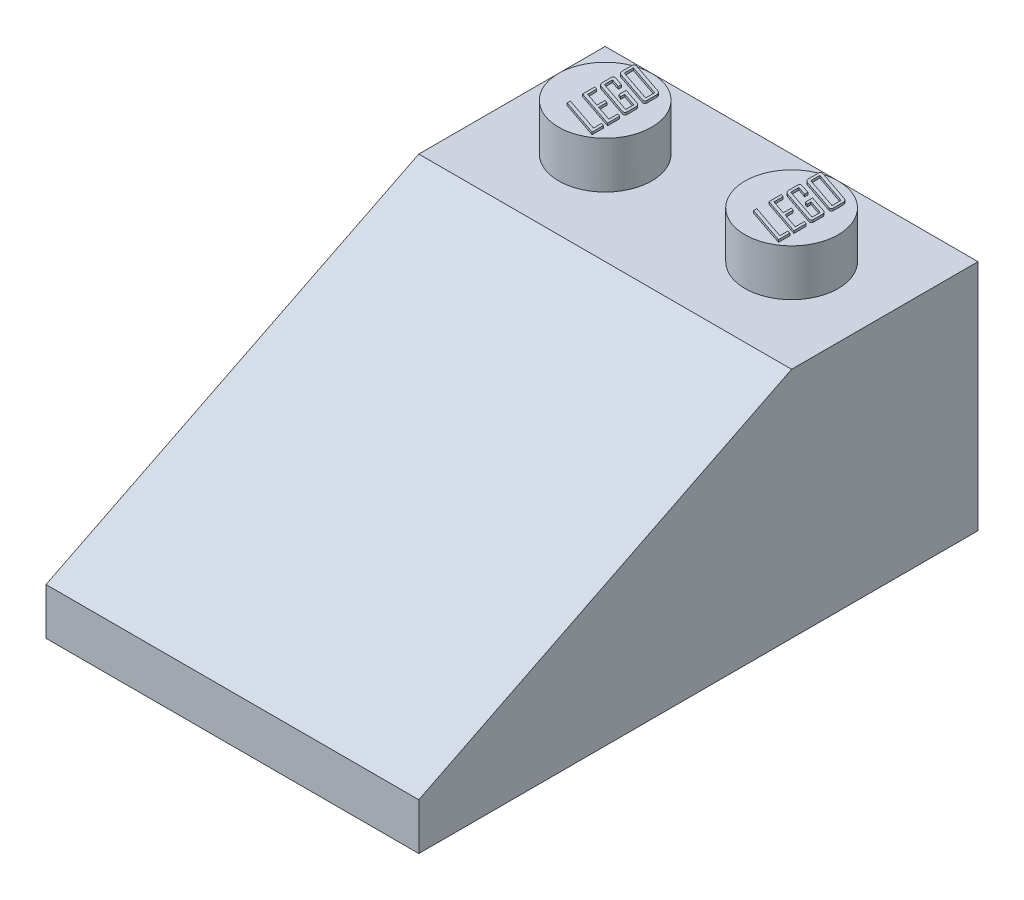
from build123d import *

# Parameters (mm, degrees)
BOSS_EXTRUDE1_DEPTH = 16
SKETCH2_R           = 2
BOSS_EXTRUDE2_DEPTH = 2
SHELL1_T            = -1
BOSS_EXTRUDE3_REACH = 14
SKETCH3_R           = 2.7
SKETCH3_R_2         = 1.7
BOSS_EXTRUDE6_DEPTH = 0.1
BOSS_EXTRUDE7_DEPTH = 0.1


with BuildPart() as part:
    # Sketch1 → Boss-Extrude1 (new body)
    with BuildSketch(Plane(origin=(0, 0, 0), x_dir=(0, 0, -1), z_dir=(1, 0, 0))):
        Polygon((-24, 0), (0, 0), (0, 10), (-8, 10), (-24, 2), align=None)
    extrude(amount=BOSS_EXTRUDE1_DEPTH)

    # Sketch2 → Boss-Extrude2 (add)
    with BuildSketch(Plane(origin=(0, 10, 0), x_dir=(1, 0, 0), z_dir=(0, 1, 0))):
        with Locations((4, -4)):
            Circle(SKETCH2_R)
        with Locations((12, -4)):
            Circle(SKETCH2_R)
    extrude(amount=BOSS_EXTRUDE2_DEPTH)

    # Shell1
    shell1_openings = [part.faces().sort_by_distance(p)[0] for p in [
        (8, 0, 12),
    ]]
    offset(amount=SHELL1_T, openings=shell1_openings, kind=Kind.INTERSECTION)

    # Sketch3 → Boss-Extrude3 (add, up to next)
    with BuildSketch(Plane.XZ, mode=Mode.PRIVATE) as boss_extrude3_sk1:
        with Locations((8, 8)):
            Circle(SKETCH3_R)
        with Locations((8, 8)):
            Circle(SKETCH3_R_2, mode=Mode.SUBTRACT)
    boss_extrude3_tool1 = extrude(boss_extrude3_sk1.sketch, amount=-BOSS_EXTRUDE3_REACH, mode=Mode.PRIVATE) - part.part
    add(boss_extrude3_tool1.solids().sort_by_distance((5.376368, 0, 8))[0])
    # Sketch3 → Boss-Extrude3 (add, up to next)
    with BuildSketch(Plane.XZ, mode=Mode.PRIVATE) as boss_extrude3_sk2:
        with Locations((8, 16)):
            Circle(SKETCH3_R)
        with Locations((8, 16)):
            Circle(SKETCH3_R_2, mode=Mode.SUBTRACT)
    boss_extrude3_tool2 = extrude(boss_extrude3_sk2.sketch, amount=-BOSS_EXTRUDE3_REACH, mode=Mode.PRIVATE) - part.part
    add(boss_extrude3_tool2.solids().sort_by_distance((5.376368, 0, 16))[0])

    # Sketch4 → Boss-Extrude6 (add)
    with BuildSketch(Plane(origin=(0, 12, 0), x_dir=(1, 0, 0), z_dir=(0, 1, 0))):
        Polygon((5, -5.07639621), (5, -5.563586671), (3.382527669, -5.013974932), (3.382527669, -4.877561603), (4.883074289, -5.387284623), (4.883074289, -5.036507491), align=None)
        Polygon((5, -4.375816327), (5, -4.901982025), (3.382527669, -4.352370286), (3.382527669, -3.826204588), (3.49945338, -3.865788813), (3.49945338, -4.255541182), (4.103569552, -4.460770163), (4.103569552, -4.109993032), (4.220495262, -4.149881751), (4.220495262, -4.500658882), (4.883074289, -4.725679977), (4.883074289, -4.335927608), align=None)
        with BuildLine():
            add(Edge.make_bspline(
                [(4.880638337, -3.517813026), (4.889199859, -3.521081683), (4.906042929, -3.527512106), (4.928863276, -3.542064932), (4.949502835, -3.559372092), (4.966947172, -3.580182774), (4.981499259, -3.602746648), (4.992465511, -3.626650767), (4.998722026, -3.651879609), (4.999570898, -3.669012008), (5, -3.677672396)],
                knots=[0, 0, 0, 0, 2.7428e-05, 5.3959e-05, 8.0744e-05, 0.000107959, 0.000135072, 0.000161104, 0.000186509, 0.000212479, 0.000212479, 0.000212479, 0.000212479], degree=3))
            Line((5, -3.677672396), (5, -4.06255286))
            add(Edge.make_bspline(
                [(5, -4.06255286), (4.999606754, -4.070705946), (4.998866417, -4.086055188), (4.992979137, -4.107517184), (4.981844322, -4.124889212), (4.967036047, -4.138214779), (4.948801843, -4.147092769), (4.927819264, -4.150147032), (4.904591861, -4.148459065), (4.888995283, -4.143873728), (4.880638337, -4.141416816)],
                knots=[0, 0, 0, 0, 2.4453e-05, 4.6035e-05, 6.5886e-05, 8.5509e-05, 0.000105119, 0.000125794, 0.000148378, 0.000174447, 0.000174447, 0.000174447, 0.000174447], degree=3))
            Line((4.880638337, -4.141416816), (3.501889332, -3.672800492))
            add(Edge.make_bspline(
                [(3.501889332, -3.672800492), (3.4933245, -3.669536063), (3.476474918, -3.663113957), (3.453757702, -3.648535645), (3.432927685, -3.631470812), (3.415304159, -3.610808853), (3.40056938, -3.588179121), (3.390203588, -3.56395811), (3.383773024, -3.53874798), (3.382945819, -3.521606234), (3.382527669, -3.512941121)],
                knots=[0, 0, 0, 0, 2.7428e-05, 5.3959e-05, 8.0548e-05, 0.000107961, 0.000135075, 0.000161263, 0.000186668, 0.000212637, 0.000212637, 0.000212637, 0.000212637], degree=3))
            Line((3.382527669, -3.512941121), (3.382527669, -3.128060657))
            add(Edge.make_bspline(
                [(3.382527669, -3.128060657), (3.382910659, -3.119900586), (3.383631686, -3.104538193), (3.389632642, -3.083216169), (3.400247525, -3.065643916), (3.415371427, -3.052622347), (3.433671653, -3.043968349), (3.454669794, -3.040338163), (3.477942339, -3.042193312), (3.493534664, -3.046753347), (3.501889332, -3.049196701)],
                knots=[0, 0, 0, 0, 2.4453e-05, 4.6035e-05, 6.5724e-05, 8.5145e-05, 0.00010503, 0.000125756, 0.00014834, 0.00017441, 0.00017441, 0.00017441, 0.00017441], degree=3))
            Line((3.501889332, -3.049196701), (3.86971813, -3.174039257))
            Line((3.86971813, -3.174039257), (3.86971813, -3.310452586))
            Line((3.86971813, -3.310452586), (3.49945338, -3.184696548))
            Line((3.49945338, -3.184696548), (3.49945338, -3.53547368))
            Line((3.49945338, -3.53547368), (4.883074289, -4.005612475))
            Line((4.883074289, -4.005612475), (4.883074289, -3.654835343))
            Line((4.883074289, -3.654835343), (4.298445736, -3.45630523))
            Line((4.298445736, -3.45630523), (4.298445736, -3.631693796))
            Line((4.298445736, -3.631693796), (4.181520025, -3.591805077))
            Line((4.181520025, -3.591805077), (4.181520025, -3.280003182))
            Line((4.181520025, -3.280003182), (4.880638337, -3.517813026))
        make_face()
        with BuildLine():
            add(Edge.make_bspline(
                [(4.880638337, -2.622356959), (4.889199849, -2.625625617), (4.906042901, -2.632056045), (4.928863385, -2.646608841), (4.949502421, -2.663916116), (4.966948743, -2.684726357), (4.98149352, -2.707291854), (4.992527158, -2.731280171), (4.998661554, -2.756537274), (4.99955405, -2.773660455), (5, -2.782216329)],
                knots=[0, 0, 0, 0, 2.7428e-05, 5.3959e-05, 8.0744e-05, 0.000107959, 0.000135072, 0.000161104, 0.000186805, 0.000212471, 0.000212471, 0.000212471, 0.000212471], degree=3))
            Line((5, -2.782216329), (5, -3.20607203))
            add(Edge.make_bspline(
                [(5, -3.20607203), (4.999606754, -3.214225115), (4.998866417, -3.229574358), (4.992979137, -3.251036354), (4.981844322, -3.268408381), (4.967036047, -3.281733948), (4.948801843, -3.290611938), (4.927819264, -3.293666201), (4.904591861, -3.291978234), (4.888995283, -3.287392897), (4.880638337, -3.284935986)],
                knots=[0, 0, 0, 0, 2.4453e-05, 4.6035e-05, 6.5886e-05, 8.5509e-05, 0.000105119, 0.000125794, 0.000148378, 0.000174447, 0.000174447, 0.000174447, 0.000174447], degree=3))
            Line((4.880638337, -3.284935986), (3.501889332, -2.816319661))
            add(Edge.make_bspline(
                [(3.501889332, -2.816319661), (3.4933245, -2.813055232), (3.476474918, -2.806633127), (3.453757702, -2.792054815), (3.432927685, -2.774989982), (3.415304159, -2.754328023), (3.40056938, -2.731698291), (3.390203588, -2.707477279), (3.383773024, -2.682267149), (3.382945819, -2.665125404), (3.382527669, -2.656460291)],
                knots=[0, 0, 0, 0, 2.7428e-05, 5.3959e-05, 8.0548e-05, 0.000107961, 0.000135075, 0.000161263, 0.000186668, 0.000212637, 0.000212637, 0.000212637, 0.000212637], degree=3))
            Line((3.382527669, -2.656460291), (3.382527669, -2.23260459))
            add(Edge.make_bspline(
                [(3.382527669, -2.23260459), (3.382898454, -2.224442674), (3.383592079, -2.209174255), (3.389685605, -2.187965858), (3.400338096, -2.170499732), (3.415258624, -2.157137097), (3.43368607, -2.148528669), (3.454665509, -2.144877225), (3.477943649, -2.146738734), (3.493535121, -2.151297799), (3.501889332, -2.153740634)],
                knots=[0, 0, 0, 0, 2.4453e-05, 4.5743e-05, 6.5432e-05, 8.5055e-05, 0.00010494, 0.000125666, 0.00014825, 0.000174319, 0.000174319, 0.000174319, 0.000174319], degree=3))
            Line((3.501889332, -2.153740634), (4.880638337, -2.622356959))
        make_face()
        Polygon((4.883074289, -2.759379276), (3.49945338, -2.289240481), (3.49945338, -2.67899285), (4.883074289, -3.149131645), align=None, mode=Mode.SUBTRACT)
    extrude(amount=BOSS_EXTRUDE6_DEPTH)

    # Sketch5 → Boss-Extrude7 (add)
    with BuildSketch(Plane(origin=(0, 12, 0), x_dir=(1, 0, 0), z_dir=(0, 1, 0))):
        Polygon((13, -5.07639621), (13, -5.563586671), (11.382527669, -5.013974932), (11.382527669, -4.877561603), (12.883074289, -5.387284623), (12.883074289, -5.036507491), align=None)
        Polygon((13, -4.375816327), (13, -4.901982025), (11.382527669, -4.352370286), (11.382527669, -3.826204588), (11.49945338, -3.865788813), (11.49945338, -4.255541182), (12.103569552, -4.460770163), (12.103569552, -4.109993032), (12.220495262, -4.149881751), (12.220495262, -4.500658882), (12.883074289, -4.725679977), (12.883074289, -4.335927608), align=None)
        with BuildLine():
            add(Edge.make_bspline(
                [(12.880638337, -3.517813026), (12.889199859, -3.521081683), (12.906042929, -3.527512106), (12.928863276, -3.542064932), (12.949502835, -3.559372092), (12.966947172, -3.580182774), (12.981499259, -3.602746648), (12.992465511, -3.626650767), (12.998722026, -3.651879609), (12.999570898, -3.669012008), (13, -3.677672396)],
                knots=[0, 0, 0, 0, 2.7428e-05, 5.3959e-05, 8.0744e-05, 0.000107959, 0.000135072, 0.000161104, 0.000186509, 0.000212479, 0.000212479, 0.000212479, 0.000212479], degree=3))
            Line((13, -3.677672396), (13, -4.06255286))
            add(Edge.make_bspline(
                [(13, -4.06255286), (12.999606754, -4.070705946), (12.998866417, -4.086055188), (12.992979137, -4.107517184), (12.981844322, -4.124889212), (12.967036047, -4.138214779), (12.948801843, -4.147092769), (12.927819264, -4.150147032), (12.904591861, -4.148459065), (12.888995283, -4.143873728), (12.880638337, -4.141416816)],
                knots=[0, 0, 0, 0, 2.4453e-05, 4.6035e-05, 6.5886e-05, 8.5509e-05, 0.000105119, 0.000125794, 0.000148378, 0.000174447, 0.000174447, 0.000174447, 0.000174447], degree=3))
            Line((12.880638337, -4.141416816), (11.501889332, -3.672800492))
            add(Edge.make_bspline(
                [(11.501889332, -3.672800492), (11.4933245, -3.669536063), (11.476474918, -3.663113957), (11.453757702, -3.648535645), (11.432927685, -3.631470812), (11.415304159, -3.610808853), (11.40056938, -3.588179121), (11.390203588, -3.56395811), (11.383773024, -3.53874798), (11.382945819, -3.521606234), (11.382527669, -3.512941121)],
                knots=[0, 0, 0, 0, 2.7428e-05, 5.3959e-05, 8.0548e-05, 0.000107961, 0.000135075, 0.000161263, 0.000186668, 0.000212637, 0.000212637, 0.000212637, 0.000212637], degree=3))
            Line((11.382527669, -3.512941121), (11.382527669, -3.128060657))
            add(Edge.make_bspline(
                [(11.382527669, -3.128060657), (11.382910659, -3.119900586), (11.383631686, -3.104538193), (11.389632642, -3.083216169), (11.400247525, -3.065643916), (11.415371427, -3.052622347), (11.433671653, -3.043968349), (11.454669794, -3.040338163), (11.477942339, -3.042193312), (11.493534664, -3.046753347), (11.501889332, -3.049196701)],
                knots=[0, 0, 0, 0, 2.4453e-05, 4.6035e-05, 6.5724e-05, 8.5145e-05, 0.00010503, 0.000125756, 0.00014834, 0.00017441, 0.00017441, 0.00017441, 0.00017441], degree=3))
            Line((11.501889332, -3.049196701), (11.86971813, -3.174039257))
            Line((11.86971813, -3.174039257), (11.86971813, -3.310452586))
            Line((11.86971813, -3.310452586), (11.49945338, -3.184696548))
            Line((11.49945338, -3.184696548), (11.49945338, -3.53547368))
            Line((11.49945338, -3.53547368), (12.883074289, -4.005612475))
            Line((12.883074289, -4.005612475), (12.883074289, -3.654835343))
            Line((12.883074289, -3.654835343), (12.298445736, -3.45630523))
            Line((12.298445736, -3.45630523), (12.298445736, -3.631693796))
            Line((12.298445736, -3.631693796), (12.181520025, -3.591805077))
            Line((12.181520025, -3.591805077), (12.181520025, -3.280003182))
            Line((12.181520025, -3.280003182), (12.880638337, -3.517813026))
        make_face()
        with BuildLine():
            add(Edge.make_bspline(
                [(12.880638337, -2.622356959), (12.889199849, -2.625625617), (12.906042901, -2.632056045), (12.928863385, -2.646608841), (12.949502421, -2.663916116), (12.966948743, -2.684726357), (12.98149352, -2.707291854), (12.992527158, -2.731280171), (12.998661554, -2.756537274), (12.99955405, -2.773660455), (13, -2.782216329)],
                knots=[0, 0, 0, 0, 2.7428e-05, 5.3959e-05, 8.0744e-05, 0.000107959, 0.000135072, 0.000161104, 0.000186805, 0.000212471, 0.000212471, 0.000212471, 0.000212471], degree=3))
            Line((13, -2.782216329), (13, -3.20607203))
            add(Edge.make_bspline(
                [(13, -3.20607203), (12.999606754, -3.214225115), (12.998866417, -3.229574358), (12.992979137, -3.251036354), (12.981844322, -3.268408381), (12.967036047, -3.281733948), (12.948801843, -3.290611938), (12.927819264, -3.293666201), (12.904591861, -3.291978234), (12.888995283, -3.287392897), (12.880638337, -3.284935986)],
                knots=[0, 0, 0, 0, 2.4453e-05, 4.6035e-05, 6.5886e-05, 8.5509e-05, 0.000105119, 0.000125794, 0.000148378, 0.000174447, 0.000174447, 0.000174447, 0.000174447], degree=3))
            Line((12.880638337, -3.284935986), (11.501889332, -2.816319661))
            add(Edge.make_bspline(
                [(11.501889332, -2.816319661), (11.4933245, -2.813055232), (11.476474918, -2.806633127), (11.453757702, -2.792054815), (11.432927685, -2.774989982), (11.415304159, -2.754328023), (11.40056938, -2.731698291), (11.390203588, -2.707477279), (11.383773024, -2.682267149), (11.382945819, -2.665125404), (11.382527669, -2.656460291)],
                knots=[0, 0, 0, 0, 2.7428e-05, 5.3959e-05, 8.0548e-05, 0.000107961, 0.000135075, 0.000161263, 0.000186668, 0.000212637, 0.000212637, 0.000212637, 0.000212637], degree=3))
            Line((11.382527669, -2.656460291), (11.382527669, -2.23260459))
            add(Edge.make_bspline(
                [(11.382527669, -2.23260459), (11.382898454, -2.224442674), (11.383592079, -2.209174255), (11.389685605, -2.187965858), (11.400338096, -2.170499732), (11.415258624, -2.157137097), (11.43368607, -2.148528669), (11.454665509, -2.144877225), (11.477943649, -2.146738734), (11.493535121, -2.151297799), (11.501889332, -2.153740634)],
                knots=[0, 0, 0, 0, 2.4453e-05, 4.5743e-05, 6.5432e-05, 8.5055e-05, 0.00010494, 0.000125666, 0.00014825, 0.000174319, 0.000174319, 0.000174319, 0.000174319], degree=3))
            Line((11.501889332, -2.153740634), (12.880638337, -2.622356959))
        make_face()
        Polygon((12.883074289, -2.759379276), (11.49945338, -2.289240481), (11.49945338, -2.67899285), (12.883074289, -3.149131645), align=None, mode=Mode.SUBTRACT)
    extrude(amount=BOSS_EXTRUDE7_DEPTH)


solid = part.part
